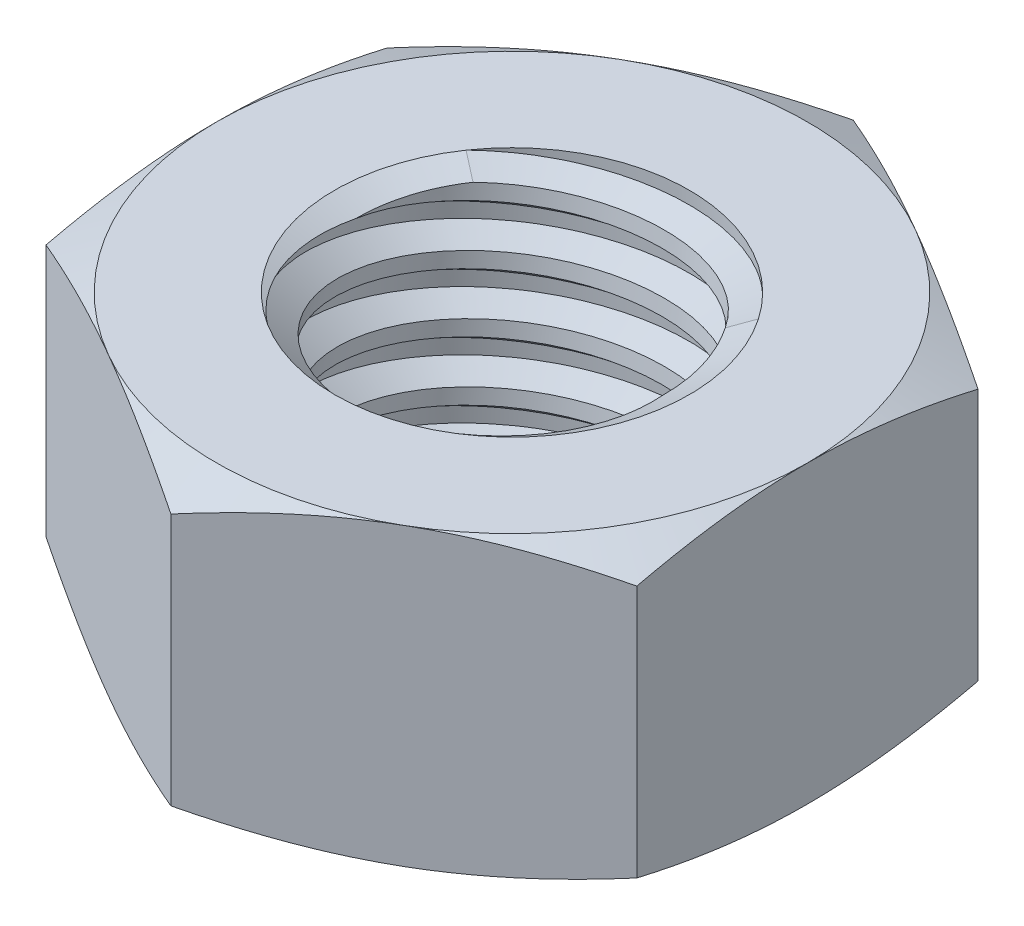
from build123d import *

# Parameters (mm, degrees)
EXTRUDE1_DEPTH       = 2.5
SKETCH2_W            = 3
SKETCH2_H            = 5
LPATTERN1_COUNT      = 5
LPATTERN1_PITCH      = 1
LPATTERN1_COUNT_DIR2 = 2
LPATTERN1_PITCH_DIR2 = 1


with BuildPart() as part:
    # Sketch1 → Extrude1 (new, symmetric)
    with BuildSketch(Plane(origin=(0, 0, 0), x_dir=(1, 0, 0), z_dir=(0, 1, 0))):
        Polygon((0, 5.773502692), (-5, 2.886751346), (-5, -2.886751346), (0, -5.773502692), (5, -2.886751346), (5, 2.886751346), align=None)
    extrude(amount=EXTRUDE1_DEPTH, both=True)

    # Sketch4 → Cut-Revolve2 (revolve, cut)
    with BuildSketch(Plane(origin=(0, 0, 0), x_dir=(0, 0, -1), z_dir=(1, 0, 0))):
        Polygon((0, 2.5), (3, 2.5), (2.538023184, 2.284576673), (2.538023184, -2.284576673), (3, -2.5), (0, -2.5), align=None)
    revolve(axis=Axis((0, 2.5, 0), (0, 1, 0)), mode=Mode.SUBTRACT)


with BuildPart() as body_2:
    # Sketch2 → Revolve1 (revolve)
    with BuildSketch(Plane(origin=(0, 0, 0), x_dir=(0, 0, -1), z_dir=(1, 0, 0))):
        with Locations((1.5, 0)):
            Rectangle(SKETCH2_W, SKETCH2_H)
    revolve(axis=Axis((0, -5.5, 0), (0, 1, 0)))

    # Sketch3 → Cut-Revolve1 (revolve, cut)
    with BuildSketch(Plane(origin=(0, 0, 0), x_dir=(0, 0, -1), z_dir=(1, 0, 0))):
        Polygon((-3.020549873, 2.37670076), (-3.164398987, 1.513606076), (-2.579122931, 1.732870615), (-2.538023184, 1.979469096), align=None)
    cut_revolve1 = revolve(axis=Axis((0, 2.5, -0.178376498), (0, -0.9863939238321437, 0.1643989873053574)), mode=Mode.SUBTRACT)

    # LPattern1: Cut-Revolve1 5 × 2
    with Locations(*[Vector(0, -1, 0) * (i * LPATTERN1_PITCH) + Vector(0, 1, 0) * (j * LPATTERN1_PITCH_DIR2) for i in range(LPATTERN1_COUNT) for j in range(LPATTERN1_COUNT_DIR2) if (i, j) != (0, 0)]):
        add(cut_revolve1, mode=Mode.SUBTRACT)


with BuildPart() as part_1:
    add(part.part)

    # Combine1: cut body 2
    add(body_2.part, mode=Mode.SUBTRACT)

    # Sketch5 → Cut-Revolve3 (revolve, cut)
    with BuildSketch(Plane(origin=(0, 0, 0), x_dir=(0, 0, -1), z_dir=(1, 0, 0))):
        Polygon((0, -2.5), (5, -2.5), (5.773502692, -2.139309771), (5.773502692, 2.139309771), (5, 2.5), (0, 2.5), (0, 3.77), (7.043502692, 3.77), (7.043502692, -3.77), (0, -3.77), align=None)
    revolve(axis=Axis((0, -2.5, 0), (0, 1, 0)), mode=Mode.SUBTRACT)


solid = part_1.part
